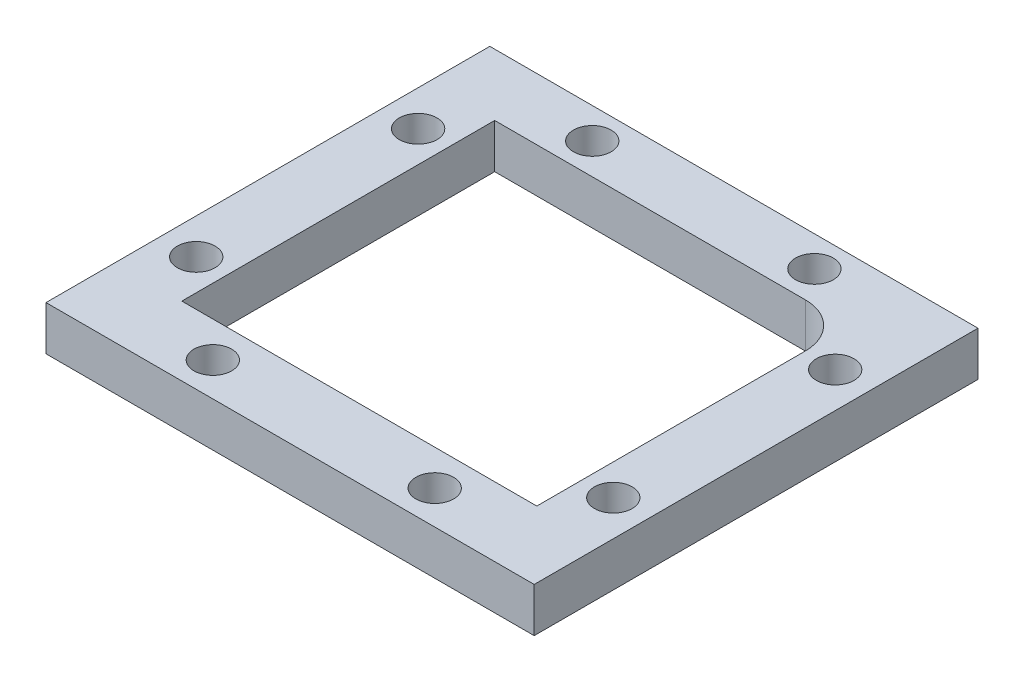
from build123d import *

# Parameters (mm, degrees)
CROQUIS1_R                              = 15.25
CROQUIS1_R_2                            = 2.125
SOPORTE_CAJA_REDUCTORA_DEPTH            = 20
CROQUIS3_R                              = 2.125
CORTAR_EXTRUIR1_DEPTH                   = 51.423828692
REDONDEO1_R                             = 5
BOSS_EXTRUDE1_DEPTH                     = 20
CUT_EXTRUDE1_REACH                      = 55.852
SKETCH2_R                               = 1.625
CUT_EXTRUDE2_DEPTH                      = 2
SKETCH4_R                               = 1.625
CUT_EXTRUDE3_DEPTH                      = 63.291652731
CUT_EXTRUDE4_START                      = -4.5
CUT_EXTRUDE4_DEPTH                      = 2
CROQUIS6_W                              = 4.75
CROQUIS6_H                              = 4.75
CORTAR_EXTRUIR17_DEPTH                  = 42.231056256
CROQUIS7_W                              = 60
CROQUIS7_H                              = 20
CORTAR_EXTRUIR18_DEPTH                  = 51.423828692
SALIENTE_EXTRUIR2_DEPTH                 = 49
SOPORTE_START                           = -15
SOPORTE_MOTOR_DEPTH                     = 15
CROQUIS12_R                             = 2.125
AGUJEROS_DE_SUJECION_A_BASE_DEPTH       = 84.087679592
TUERCA_START                            = -4
TUERCA_AGUJERO_DE_SUJECION_A_BASE_DEPTH = 10
SALIENTE_EXTRUIR4_DEPTH                 = 15
CORTAR_EXTRUIR19_DEPTH                  = 25
CROQUIS14_W                             = 50
CROQUIS14_H                             = 118
CORTAR_EXTRUIR22_DEPTH                  = 146.556045907
CROQUIS15_W                             = 10
CROQUIS15_H                             = 7
CORTAR_EXTRUIR23_DEPTH                  = 42.231056256
CORTAR_EXTRUIR24_DEPTH                  = 42.231056256
CROQUIS18_W                             = 40
CROQUIS18_H                             = 10
CORTAR_EXTRUIR25_DEPTH                  = 44.27311521
SALIENTE_EXTRUIR5_DEPTH                 = 10
CROQUIS20_R                             = 1
CORTAR_EXTRUIR26_DEPTH                  = 49.229270158
CORTAR_EXTRUIR27_REACH                  = 62.959
CORTAR_EXTRUIR27_END_RADIUS             = 15.25
CROQUIS21_R                             = 1.625
CROQUIS22_R                             = 2.125
CROQUIS22_R_2                           = 1
SALIENTE_EXTRUIR6_DEPTH                 = 10
CROQUIS23_R                             = 1.625
CORTAR_EXTRUIR28_DEPTH                  = 52.269508521
CORTAR_EXTRUIR29_START                  = -3
CORTAR_EXTRUIR29_DEPTH                  = 10
SALIENTE_EXTRUIR7_DEPTH                 = 10
CORTAR_EXTRUIR30_REACH                  = 72.235
CROQUIS27_R                             = 1.625
CORTAR_EXTRUIR31_REACH                  = 75.235
CORTAR_EXTRUIR31_START                  = -3
CORTAR_EXTRUIR32_REACH                  = 58.612
CROQUIS29_R                             = 1.625
CORTAR_EXTRUIR33_REACH                  = 61.112
CORTAR_EXTRUIR33_START                  = -2.5
CROQUIS35_W                             = 13.305418987
CROQUIS35_H                             = 6.826864192
CORTAR_EXTRUIR34_DEPTH                  = 63.931555098
CORTAR_EXTRUIR34_DEPTH_BACK             = 63.931555098
CORTAR_EXTRUIR35_START                  = -3
CORTAR_EXTRUIR35_DEPTH                  = 10
SALIENTE_EXTRUIR8_DEPTH                 = 10
SALIENTE_EXTRUIR9_DEPTH                 = 13
SALIENTE_EXTRUIR10_DEPTH                = 3
CROQUIS40_W                             = 106.583537839
CROQUIS40_H                             = 47.391515964
CORTAR_EXTRUIR36_DEPTH                  = 80.887064817
CORTAR_EXTRUIR36_DEPTH_BACK             = 80.887064817
CORTAR_EXTRUIR37_DEPTH                  = 67.2524009
CORTAR_EXTRUIR37_DEPTH_BACK             = 67.2524009
CORTAR_EXTRUIR38_DEPTH                  = 79.704784639
CORTAR_EXTRUIR38_DEPTH_BACK             = 79.704784639
SALIENTE_EXTRUIR11_DEPTH                = 10
CORTAR_EXTRUIR39_DEPTH                  = 63.9908649
CROQUIS45_W                             = 31.470301378
CROQUIS45_H                             = 10
CROQUIS45_R                             = 1.625
SALIENTE_EXTRUIR12_DEPTH                = 2.5
SALIENTE_EXTRUIR13_DEPTH                = 10
CORTAR_EXTRUIR40_START                  = -2
CROQUIS47_R                             = 1.625
CORTAR_EXTRUIR40_DEPTH                  = 10
CORTAR_EXTRUIR41_START                  = -12
CROQUIS48_R                             = 1.625
CORTAR_EXTRUIR41_DEPTH                  = 12
CROQUIS49_W                             = 34.796066513
CROQUIS49_H                             = 42.211026982
CORTAR_EXTRUIR42_DEPTH                  = 52.795622989
CORTAR_EXTRUIR42_DEPTH_BACK             = 52.795622989
CROQUIS51_R                             = 15.25
CROQUIS51_R_2                           = 14.25
SALIENTE_EXTRUIR14_DEPTH                = 10
CORTAR_EXTRUIR43_DEPTH                  = 10
CORTAR_EXTRUIR44_DEPTH                  = 10
CORTAR_EXTRUIR45_DEPTH                  = 10
SALIENTE_EXTRUIR15_DEPTH                = 10
CROQUIS56_W                             = 55
CROQUIS56_H                             = 50
SALIENTE_EXTRUIR16_DEPTH                = 5
CROQUIS57_W                             = 42.651963039
CROQUIS57_H                             = 12.802181648
CORTAR_EXTRUIR46_DEPTH                  = 71.545387859
CORTAR_EXTRUIR46_DEPTH_BACK             = 71.545387859
CROQUIS58_R                             = 2.125
CORTAR_EXTRUIR47_DEPTH                  = 5


with BuildPart() as part:
    # Croquis1 → Soporte caja reductora (new body)
    with BuildSketch(Plane(origin=(0, 0, 0), x_dir=(1, 0, 0), z_dir=(0, 1, 0))):
        Polygon((-30, -15.25), (-20, -15.25), (-20, -20), (20, -20), (20, -15.25), (30, -15.25), (30, -7.25), (20, -4.25), (20, 20), (-20, 20), (-20, -4.25), (-30, -7.25), align=None)
        with Locations(Location((0, 0, 0), (0, 0, 270))):
            Circle(CROQUIS1_R, mode=Mode.SUBTRACT)
        with Locations(Location((-15, 15, 0), (0, 0, 270))):
            Circle(CROQUIS1_R_2, mode=Mode.SUBTRACT)
        with Locations(Location((15, 15, 0), (0, 0, 270))):
            Circle(CROQUIS1_R_2, mode=Mode.SUBTRACT)
    extrude(amount=-SOPORTE_CAJA_REDUCTORA_DEPTH)

    # Croquis3 → Cortar-Extruir1 (cut, through all)
    with BuildSketch(Plane.XY.offset(15.25)):
        with Locations((-23.5, -10)):
            Circle(CROQUIS3_R)
        with Locations((23.5, -10)):
            Circle(CROQUIS3_R)
    extrude(amount=-CORTAR_EXTRUIR1_DEPTH, mode=Mode.SUBTRACT)

    # Redondeo1
    redondeo1_edges = [part.edges().sort_by_distance(p)[0] for p in [
        (-20, -10, -20),
        (20, -10, -20),
    ]]
    fillet(redondeo1_edges, radius=REDONDEO1_R)

    # Sketch1 → Boss-Extrude1 (add)
    with BuildSketch(Plane(origin=(0, 0, 0), x_dir=(1, 0, 0), z_dir=(0, 1, 0))):
        with BuildLine():
            Line((25.5, 15), (20, 15))
            ThreePointArc((20, 15), (18.535533906, 18.535533906), (15, 20))
            Line((15, 20), (30, 20))
            Line((30, 20), (30, 8))
            Line((30, 8), (25.5, 8))
            Line((25.5, 8), (25.5, 15))
        make_face()
    extrude(amount=-BOSS_EXTRUDE1_DEPTH)

    # Sketch2 → Cut-Extrude1 (cut, up to next)
    with BuildSketch(Plane(origin=(0, 0, -20), x_dir=(-1, 0, 0), z_dir=(0, 0, -1)), mode=Mode.PRIVATE) as cut_extrude1_sk1:
        with Locations((-22.75, -10)):
            Circle(SKETCH2_R)
    cut_extrude1_tool1 = extrude(cut_extrude1_sk1.sketch, amount=-CUT_EXTRUDE1_REACH, mode=Mode.PRIVATE) & part.part
    add(cut_extrude1_tool1.solids().sort_by_distance((22.75, -10, -20))[0], mode=Mode.SUBTRACT)

    # Sketch3 → Cut-Extrude2 (cut)
    with BuildSketch(Plane.XY.offset(-15)):
        Polygon((20, -11.58771324), (22.75, -13.175426481), (25.5, -11.58771324), (25.5, -8.41228676), (22.75, -6.824573519), (20, -8.41228676), align=None)
    extrude(amount=-CUT_EXTRUDE2_DEPTH, mode=Mode.SUBTRACT)

    # Sketch4 → Cut-Extrude3 (cut, through all)
    with BuildSketch(Plane.ZY.offset(-25.5)):
        with Locations((-12.25, -10)):
            Circle(SKETCH4_R)
    extrude(amount=-CUT_EXTRUDE3_DEPTH, mode=Mode.SUBTRACT)

    # Sketch5 → Cut-Extrude4 (cut)
    with BuildSketch(Plane(origin=(30, 0, 0), x_dir=(0, 0, -1), z_dir=(1, 0, 0)).offset(CUT_EXTRUDE4_START)):
        Polygon((15, -11.58771324), (15, -8.41228676), (12.25, -6.824573519), (9.5, -8.41228676), (9.5, -11.58771324), (12.25, -13.175426481), align=None)
    extrude(amount=CUT_EXTRUDE4_DEPTH, mode=Mode.SUBTRACT)

    # Croquis6 → Cortar-Extruir17 (cut, through all)
    with BuildSketch(Plane(origin=(0, 0, 0), x_dir=(1, 0, 0), z_dir=(0, 1, 0))):
        Polygon((0, -15.25), (-15.25, -15.25), (-15.25, -20), (15.25, -20), (15.25, -15.25), align=None)
        with Locations((-17.625, -17.625)):
            Rectangle(CROQUIS6_W, CROQUIS6_H)
        with BuildLine():
            ThreePointArc((0, -15.25), (-10.783378413, -10.783378413), (-15.25, 0))
            Line((-15.25, 0), (-15.25, -15.25))
            Line((-15.25, -15.25), (0, -15.25))
        make_face()
        with BuildLine():
            Line((15.25, -15.25), (15.25, 0))
            ThreePointArc((15.25, 0), (10.783378413, -10.783378413), (0, -15.25))
            Line((0, -15.25), (15.25, -15.25))
        make_face()
        with Locations((17.625, -17.625)):
            Rectangle(CROQUIS6_W, CROQUIS6_H)
    extrude(amount=-CORTAR_EXTRUIR17_DEPTH, mode=Mode.SUBTRACT)


with BuildPart() as body_2:
    # Simetría1: mirrored copy
    add(part.part.mirror(Plane.ZX))

    # Croquis8 → Saliente-Extruir2 (add)
    with BuildSketch(Plane(origin=(0, 20, 0), x_dir=(1, 0, 0), z_dir=(0, 1, 0))):
        with BuildLine():
            Line((-12.664515522, 20), (-11.040489496, 13.939052358))
            Line((-11.040489496, 13.939052358), (-10.315162126, 11.232093763))
            ThreePointArc((-10.315162126, 11.232093763), (0, 15.25), (10.315162126, 11.232093763))
            Line((10.315162126, 11.232093763), (10.817418481, 13.87928066))
            Line((10.817418481, 13.87928066), (11.978715476, 20))
            Line((11.978715476, 20), (-12.664515522, 20))
        make_face()
    extrude(amount=SALIENTE_EXTRUIR2_DEPTH)

    # Croquis9 → Soporte motor (add)
    with BuildSketch(Plane(origin=(0, 69, 0), x_dir=(1, 0, 0), z_dir=(0, 1, 0)).offset(SOPORTE_START)):
        with BuildLine():
            Line((-20, 15), (-20, -4.25))
            Line((-20, -4.25), (-30, -7.25))
            Line((-30, -7.25), (-30, -15.25))
            Line((-30, -15.25), (0, -15.25))
            Line((0, -15.25), (0, -14.75))
            ThreePointArc((0, -14.75), (-10.429825023, 10.429825023), (14.75, 0))
            Line((14.75, 0), (20, 0))
            Line((20, 0), (20, 13.936837101))
            Line((20, 13.936837101), (12.664515522, 20))
            Line((12.664515522, 20), (-15, 20))
            ThreePointArc((-15, 20), (-18.535533906, 18.535533906), (-20, 15))
        make_face()
    extrude(amount=-SOPORTE_MOTOR_DEPTH)

    # Croquis12 → Agujeros de sujecion a base (cut, through all)
    with BuildSketch(Plane.XY.offset(15.25)):
        with Locations((-23.5, 46.5)):
            Circle(CROQUIS12_R)
    extrude(amount=-AGUJEROS_DE_SUJECION_A_BASE_DEPTH, mode=Mode.SUBTRACT)

    # Croquis13 → Tuerca Agujero de sujecion a base (cut)
    with BuildSketch(Plane.XY.offset(15.25).offset(TUERCA_START)):
        Polygon((-20, 44.479274058), (-20, 48.520725942), (-23.5, 50.541451884), (-27, 48.520725942), (-27, 44.479274058), (-23.5, 42.458548116), align=None)
    extrude(amount=-TUERCA_AGUJERO_DE_SUJECION_A_BASE_DEPTH, mode=Mode.SUBTRACT)

    # Croquis10 → Saliente-Extruir4 (add)
    with BuildSketch(Plane(origin=(0, 69, 0), x_dir=(1, 0, 0), z_dir=(0, 1, 0))):
        with BuildLine():
            ThreePointArc((10.315162126, 11.232093763), (0, 15.25), (-10.315162126, 11.232093763))
            Line((-10.315162126, 11.232093763), (-10.16850369, 10.684757026))
            ThreePointArc((-10.16850369, 10.684757026), (0, 14.75), (10.16850369, 10.684757026))
            Line((10.16850369, 10.684757026), (10.315162126, 11.232093763))
        make_face()
    extrude(amount=-SALIENTE_EXTRUIR4_DEPTH)

    # Croquis11 → Cortar-Extruir19 (cut)
    with BuildSketch(Plane.XZ):
        with BuildLine():
            Line((15.25, 4.25), (20, 4.25))
            Line((20, 4.25), (21.972856468, 4.84185694))
            ThreePointArc((21.972856468, 4.84185694), (19.948931102, 10.40625523), (16.543503257, 15.25))
            Line((16.543503257, 15.25), (15.25, 15.25))
            Line((15.25, 15.25), (15.25, 4.25))
        make_face()
        with BuildLine():
            Line((21.972856468, 4.84185694), (30, 7.25))
            Line((30, 7.25), (30, 15.25))
            Line((30, 15.25), (16.543503257, 15.25))
            ThreePointArc((16.543503257, 15.25), (19.948931102, 10.40625523), (21.972856468, 4.84185694))
        make_face()
        with BuildLine():
            ThreePointArc((20, -15), (18.535533906, -18.535533906), (15, -20))
            Line((15, -20), (30, -20))
            Line((30, -20), (30, -8))
            Line((30, -8), (25.5, -8))
            Line((25.5, -8), (25.5, -15))
            Line((25.5, -15), (20, -15))
        make_face()
    extrude(amount=-CORTAR_EXTRUIR19_DEPTH, mode=Mode.SUBTRACT)

    # Simetría2: body 2 across face


with BuildPart() as part_1:
    add(part.part)

    # Croquis7 → Cortar-Extruir18 (cut, through all)
    with BuildSketch(Plane(origin=(0, 0, -20), x_dir=(-1, 0, 0), z_dir=(0, 0, -1))):
        with Locations((0, -10)):
            Rectangle(CROQUIS7_W, CROQUIS7_H)
    extrude(amount=-CORTAR_EXTRUIR18_DEPTH, mode=Mode.SUBTRACT)


with BuildPart() as body_2_1:
    add(body_2.part)
    add(body_2.part.mirror(Plane(origin=(-0.229209569, 69, -16.663998028), x_dir=(0, 0, 1), z_dir=(0, 1, 0))))

    # Croquis14 → Cortar-Extruir22 (cut, through all)
    with BuildSketch(Plane.XY.offset(15.25)):
        with Locations((-5, 79)):
            Rectangle(CROQUIS14_W, CROQUIS14_H)
    extrude(amount=-CORTAR_EXTRUIR22_DEPTH, mode=Mode.SUBTRACT)

    # Croquis15 → Cortar-Extruir23 (cut, through all)
    with BuildSketch(Plane.XZ):
        with Locations((-25, 7.75)):
            Rectangle(CROQUIS15_W, CROQUIS15_H)
    extrude(amount=-CORTAR_EXTRUIR23_DEPTH, mode=Mode.SUBTRACT)

    # Croquis16 → Cortar-Extruir24 (cut, through all)
    with BuildSketch(Plane.XZ):
        Polygon((-30, 15.25), (-15.25, 15.25), (-15.25, 12.75), (-20, 12.75), (-20, 11.25), (-30, 11.25), (-30, 12.75), align=None)
    extrude(amount=-CORTAR_EXTRUIR24_DEPTH, mode=Mode.SUBTRACT)

    # Croquis18 → Cortar-Extruir25 (cut, through all)
    with BuildSketch(Plane(origin=(0, 0, -20), x_dir=(-1, 0, 0), z_dir=(0, 0, -1))):
        with Locations((0, 5)):
            Rectangle(CROQUIS18_W, CROQUIS18_H)
    extrude(amount=-CORTAR_EXTRUIR25_DEPTH, mode=Mode.SUBTRACT)

    # Croquis19 → Saliente-Extruir5 (add)
    with BuildSketch(Plane(origin=(0, 20, 0), x_dir=(1, 0, 0), z_dir=(0, 1, 0))):
        Polygon((-20, -12.75), (-34, -12.75), (-34, -7.75), (-24, -7.75), (-20, -3.75), align=None)
    extrude(amount=-SALIENTE_EXTRUIR5_DEPTH)

    # Croquis20 → Cortar-Extruir26 (cut, through all)
    with BuildSketch(Plane(origin=(0, 0, 7.75), x_dir=(-1, 0, 0), z_dir=(0, 0, -1))):
        with Locations((29, 15)):
            Circle(CROQUIS20_R)
    extrude(amount=-CORTAR_EXTRUIR26_DEPTH, mode=Mode.SUBTRACT)

    # Cortar-Extruir27: up to this cylinder (the profile starts outside it)
    cortar_extruir27_end = Plane(origin=(0, 15, 0), z_dir=(0, -1, 0)) * Cylinder(CORTAR_EXTRUIR27_END_RADIUS, 157.418, mode=Mode.PRIVATE)
    # Croquis21 → Cortar-Extruir27 (cut, up to the surface)
    with BuildSketch(Plane(origin=(20, 0, 0), x_dir=(0, 0, -1), z_dir=(1, 0, 0)), mode=Mode.PRIVATE) as cortar_extruir27_sk1:
        with Locations((4.75, 15)):
            Circle(CROQUIS21_R)
    cortar_extruir27_tool1 = extrude(cortar_extruir27_sk1.sketch, amount=-CORTAR_EXTRUIR27_REACH, mode=Mode.PRIVATE) - cortar_extruir27_end
    add(cortar_extruir27_tool1.solids().sort_by_distance((20, 15, -4.75))[0], mode=Mode.SUBTRACT)

    # Croquis22 → Saliente-Extruir6 (add)
    with BuildSketch(Plane.XZ.offset(-10)):
        with Locations((-15, -15)):
            Circle(CROQUIS22_R)
        with Locations(Location((-15, -15, 0), (0, 0, 270))):
            Circle(CROQUIS22_R_2, mode=Mode.SUBTRACT)
        with Locations((15, -15)):
            Circle(CROQUIS22_R)
        with Locations(Location((15, -15, 0), (0, 0, 270))):
            Circle(CROQUIS22_R_2, mode=Mode.SUBTRACT)
    extrude(amount=-SALIENTE_EXTRUIR6_DEPTH)

    # Croquis23 → Cortar-Extruir28 (cut, through all)
    with BuildSketch(Plane(origin=(0, 0, -20), x_dir=(-1, 0, 0), z_dir=(0, 0, -1))):
        with Locations((0, 15)):
            Circle(CROQUIS23_R)
    extrude(amount=-CORTAR_EXTRUIR28_DEPTH, mode=Mode.SUBTRACT)

    # Croquis24 → Cortar-Extruir29 (cut)
    with BuildSketch(Plane(origin=(0, 0, -20), x_dir=(-1, 0, 0), z_dir=(0, 0, -1)).offset(CORTAR_EXTRUIR29_START)):
        Polygon((1.58771324, 12.25), (3.175426481, 15), (1.58771324, 17.75), (-1.58771324, 17.75), (-3.175426481, 15), (-1.58771324, 12.25), align=None)
    extrude(amount=-CORTAR_EXTRUIR29_DEPTH, mode=Mode.SUBTRACT)

    # Croquis26 → Saliente-Extruir7 (add)
    with BuildSketch(Plane.XZ.offset(-10)):
        Polygon((-34, 7.75), (-34, 12.75), (-58.825, 12.75), (-39.160527763, -4.104491148), (-20, -4.104491148), (-20, -0.104491148), (-35.732113118, -0.104491148), (-29, 7.75), align=None)
        Polygon((-34.268209086, 7.75), (-39.594516123, 1.535690951), (-46.844874897, 7.75), align=None, mode=Mode.SUBTRACT)
    extrude(amount=-SALIENTE_EXTRUIR7_DEPTH)

    # Croquis27 → Cortar-Extruir30 (cut, up to next)
    with BuildSketch(Plane.XY.offset(12.75), mode=Mode.PRIVATE) as cortar_extruir30_sk1:
        with Locations((-40.544874897, 15)):
            Circle(CROQUIS27_R)
    cortar_extruir30_tool1 = extrude(cortar_extruir30_sk1.sketch, amount=-CORTAR_EXTRUIR30_REACH, mode=Mode.PRIVATE) & body_2_1.part
    # Croquis27 → Cortar-Extruir30 (cut, up to next)
    with BuildSketch(Plane.XY.offset(12.75), mode=Mode.PRIVATE) as cortar_extruir30_sk2:
        with Locations((-29, 15)):
            Circle(CROQUIS27_R)
    cortar_extruir30_tool2 = extrude(cortar_extruir30_sk2.sketch, amount=-CORTAR_EXTRUIR30_REACH, mode=Mode.PRIVATE) & body_2_1.part
    add(cortar_extruir30_tool1.solids().sort_by_distance((-40.544875, 15, 12.75))[0], mode=Mode.SUBTRACT)
    add(cortar_extruir30_tool2.solids().sort_by_distance((-29, 15, 12.75))[0], mode=Mode.SUBTRACT)

    # Croquis28 → Cortar-Extruir31 (cut, up to next)
    with BuildSketch(Plane.XY.offset(12.75).offset(CORTAR_EXTRUIR31_START), mode=Mode.PRIVATE) as cortar_extruir31_sk1:
        Polygon((-38.957161657, 12.25), (-37.369448416, 15), (-38.957161657, 17.75), (-42.132588137, 17.75), (-43.720301378, 15), (-42.132588137, 12.25), align=None)
    cortar_extruir31_tool1 = extrude(cortar_extruir31_sk1.sketch, amount=-CORTAR_EXTRUIR31_REACH, mode=Mode.PRIVATE) & body_2_1.part
    # Croquis28 → Cortar-Extruir31 (cut, up to next)
    with BuildSketch(Plane.XY.offset(12.75).offset(CORTAR_EXTRUIR31_START), mode=Mode.PRIVATE) as cortar_extruir31_sk2:
        Polygon((-27.41228676, 12.25), (-25.824573519, 15), (-27.41228676, 17.75), (-30.58771324, 17.75), (-32.175426481, 15), (-30.58771324, 12.25), align=None)
    cortar_extruir31_tool2 = extrude(cortar_extruir31_sk2.sketch, amount=-CORTAR_EXTRUIR31_REACH, mode=Mode.PRIVATE) & body_2_1.part
    add(cortar_extruir31_tool1.solids().sort_by_distance((-40.544875, 15, 9.75))[0], mode=Mode.SUBTRACT)
    add(cortar_extruir31_tool2.solids().sort_by_distance((-29, 15, 9.75))[0], mode=Mode.SUBTRACT)

    # Croquis29 → Cortar-Extruir32 (cut, up to next)
    with BuildSketch(Plane(origin=(-18.612848159, 0, -21.715982563), x_dir=(-0.7592713073348843, 0, 0.6507742172658468), z_dir=(-0.6507742172658468, 0, -0.7592713073348843)), mode=Mode.PRIVATE) as cortar_extruir32_sk1:
        with Locations((33.812368097, 15)):
            Circle(CROQUIS29_R)
    cortar_extruir32_tool1 = extrude(cortar_extruir32_sk1.sketch, amount=-CORTAR_EXTRUIR32_REACH, mode=Mode.PRIVATE) & body_2_1.part
    add(cortar_extruir32_tool1.solids().sort_by_distance((-44.285609, 15, 0.288235))[0], mode=Mode.SUBTRACT)

    # Croquis31 → Cortar-Extruir33 (cut, up to next)
    with BuildSketch(Plane(origin=(-18.612848159, 0, -21.715982563), x_dir=(-0.7592713073348843, 0, 0.6507742172658468), z_dir=(-0.6507742172658468, 0, -0.7592713073348843)).offset(CORTAR_EXTRUIR33_START), mode=Mode.PRIVATE) as cortar_extruir33_sk1:
        Polygon((36.562368097, 16.58771324), (33.812368097, 18.175426481), (31.062368097, 16.58771324), (31.062368097, 13.41228676), (33.812368097, 11.824573519), (36.562368097, 13.41228676), align=None)
    cortar_extruir33_tool1 = extrude(cortar_extruir33_sk1.sketch, amount=-CORTAR_EXTRUIR33_REACH, mode=Mode.PRIVATE) & body_2_1.part
    add(cortar_extruir33_tool1.solids().sort_by_distance((-42.658674, 15, 2.186413))[0], mode=Mode.SUBTRACT)

    # Croquis35 → Cortar-Extruir34 (cut, two sides)
    with BuildSketch(Plane(origin=(0, 20, 0), x_dir=(1, 0, 0), z_dir=(0, 1, 0))) as cortar_extruir34_sk:
        with Locations((17.04227466, -3.413432096)):
            Rectangle(CROQUIS35_W, CROQUIS35_H)
    extrude(amount=CORTAR_EXTRUIR34_DEPTH, mode=Mode.SUBTRACT)
    extrude(cortar_extruir34_sk.sketch, amount=-CORTAR_EXTRUIR34_DEPTH_BACK, mode=Mode.SUBTRACT)

    # Croquis36 → Cortar-Extruir35 (cut)
    with BuildSketch(Plane(origin=(20, 0, 0), x_dir=(0, 0, -1), z_dir=(1, 0, 0)).offset(CORTAR_EXTRUIR35_START)):
        Polygon((7.5, 16.58771324), (4.75, 18.175426481), (2, 16.58771324), (2, 13.41228676), (4.75, 11.824573519), (7.5, 13.41228676), align=None)
    extrude(amount=-CORTAR_EXTRUIR35_DEPTH, mode=Mode.SUBTRACT)

    # Croquis37 → Saliente-Extruir8 (add)
    with BuildSketch(Plane.XZ.offset(-10)):
        Polygon((-39.160527763, -4.104491148), (-20.614919368, -20), (-15, -20), (-19.558128305, -15.637570403), (-33.014002756, -4.104491148), align=None)
    extrude(amount=-SALIENTE_EXTRUIR8_DEPTH)

    # Croquis38 → Saliente-Extruir9 (add)
    with BuildSketch(Plane.XZ.offset(-10)):
        Polygon((-58.825, 12.75), (-38.825, 12.75), (-38.825, 9.75), (-55.324839942, 9.75), align=None)
    extrude(amount=SALIENTE_EXTRUIR9_DEPTH)

    # Croquis39 → Saliente-Extruir10 (add)
    with BuildSketch(Plane.XZ.offset(-10)):
        Polygon((-38.825, 9.75), (-38.825, 7.75), (-38.825, 5.75), (-50.657959865, 5.75), (-52.991399903, 7.75), (-55.324839942, 9.75), align=None)
    extrude(amount=SALIENTE_EXTRUIR10_DEPTH)

    # Simetría3: body 2 across face


with BuildPart() as body_2_2:
    add(body_2_1.part)
    add(body_2_1.part.mirror(Plane(origin=(-18.003999227, 20, -4.220503046), x_dir=(0, 0, 1), z_dir=(0, 1, 0))))

    # Croquis40 → Cortar-Extruir36 (cut, two sides)
    with BuildSketch(Plane(origin=(0, 0, -20), x_dir=(-1, 0, 0), z_dir=(0, 0, -1))) as cortar_extruir36_sk:
        with Locations((22.395502026, -3.695757982)):
            Rectangle(CROQUIS40_W, CROQUIS40_H)
    extrude(amount=CORTAR_EXTRUIR36_DEPTH, mode=Mode.SUBTRACT)
    extrude(cortar_extruir36_sk.sketch, amount=-CORTAR_EXTRUIR36_DEPTH_BACK, mode=Mode.SUBTRACT)

    # Croquis41 → Cortar-Extruir37 (cut, two sides)
    with BuildSketch(Plane.XZ.offset(-20)) as cortar_extruir37_sk:
        Polygon((-19.992980133, -22.302484261), (-20, 3.75), (-24, 7.75), (-56.035110209, 7.75), align=None)
    extrude(amount=CORTAR_EXTRUIR37_DEPTH, mode=Mode.SUBTRACT)
    extrude(cortar_extruir37_sk.sketch, amount=-CORTAR_EXTRUIR37_DEPTH_BACK, mode=Mode.SUBTRACT)

    # Croquis42 → Cortar-Extruir38 (cut, two sides)
    with BuildSketch(Plane(origin=(0, 0, 9.75), x_dir=(-1, 0, 0), z_dir=(0, 0, -1))) as cortar_extruir38_sk:
        Polygon((46.720301378, 20), (46.720301378, 30), (38.825, 30), (33.492952769, 43.760628779), (49.525340398, 48.951442806), (67.200390695, 42.512205152), (65.906601328, 20), (51.713995885, 13.864168239), align=None)
    extrude(amount=CORTAR_EXTRUIR38_DEPTH, mode=Mode.SUBTRACT)
    extrude(cortar_extruir38_sk.sketch, amount=-CORTAR_EXTRUIR38_DEPTH_BACK, mode=Mode.SUBTRACT)

    # Croquis43 → Saliente-Extruir11 (add)
    with BuildSketch(Plane.XZ.offset(-20)):
        Polygon((-19.993600539, -20), (-46.720301378, 7.75), (-43.839252857, 10.524807997), (-17.112552018, -17.225192003), align=None)
    extrude(amount=-SALIENTE_EXTRUIR11_DEPTH)

    # Croquis44 → Cortar-Extruir39 (cut, through all)
    with BuildSketch(Plane(origin=(0, 0, 9.75), x_dir=(-1, 0, 0), z_dir=(0, 0, -1))):
        Polygon((38.957161657, 27.75), (37.369448416, 25), (38.957161657, 22.25), (42.132588137, 22.25), (43.720301378, 25), (42.132588137, 27.75), align=None)
    extrude(amount=CORTAR_EXTRUIR39_DEPTH, mode=Mode.SUBTRACT)

    # Croquis45 → Saliente-Extruir12 (add)
    with BuildSketch(Plane.XY.offset(12.75)):
        with Locations((-30.985150689, 25)):
            Rectangle(CROQUIS45_W, CROQUIS45_H)
        with Locations((-40.544874897, 25)):
            Circle(CROQUIS45_R, mode=Mode.SUBTRACT)
        with Locations((-29, 25)):
            Circle(CROQUIS45_R, mode=Mode.SUBTRACT)
    extrude(amount=SALIENTE_EXTRUIR12_DEPTH)

    # Croquis46 → Saliente-Extruir13 (add)
    with BuildSketch(Plane.XZ.offset(-20)):
        with BuildLine():
            Line((15.25, 0), (20, 0))
            Line((20, 0), (20, 15.25))
            Line((20, 15.25), (7.549834435, 15.25))
            Line((7.549834435, 15.25), (7.549834435, 13.25))
            ThreePointArc((7.549834435, 13.25), (13.185171124, 7.662490615), (15.25, 0))
        make_face()
        with BuildLine():
            Line((-15.25, 0), (-15.25, 15.25))
            Line((-15.25, 15.25), (-7.549834435, 15.25))
            Line((-7.549834435, 15.25), (-7.549834435, 13.25))
            ThreePointArc((-7.549834435, 13.25), (-13.185171124, 7.662490615), (-15.25, 0))
        make_face()
    extrude(amount=-SALIENTE_EXTRUIR13_DEPTH)

    # Croquis47 → Cortar-Extruir40 (cut)
    with BuildSketch(Plane.XY.offset(15.25).offset(CORTAR_EXTRUIR40_START)):
        Polygon((15.41228676, 22.352505966), (17, 25.102505966), (15.41228676, 27.852505966), (12.236860279, 27.852505966), (10.649147039, 25.102505966), (12.236860279, 22.352505966), align=None)
        with Locations((13.824573519, 25.102505966)):
            Circle(CROQUIS47_R, mode=Mode.SUBTRACT)
        Polygon((-12.236860279, 22.352505966), (-15.41228676, 22.352505966), (-17, 25.102505966), (-15.41228676, 27.852505966), (-12.236860279, 27.852505966), (-10.649147039, 25.102505966), align=None)
        with Locations(Location((-13.824573519, 25.102505966, 0), (0, 0, 131.421584744))):
            Circle(CROQUIS47_R, mode=Mode.SUBTRACT)
    extrude(amount=-CORTAR_EXTRUIR40_DEPTH, mode=Mode.SUBTRACT)

    # Croquis48 → Cortar-Extruir41 (cut)
    with BuildSketch(Plane.XY.offset(15.25).offset(CORTAR_EXTRUIR41_START)):
        with Locations((13.824573519, 25.102505966)):
            Circle(CROQUIS48_R)
        with Locations((-13.824573519, 25.102505966)):
            Circle(CROQUIS48_R)
    extrude(amount=CORTAR_EXTRUIR41_DEPTH, mode=Mode.SUBTRACT)

    # Croquis49 → Cortar-Extruir42 (cut, two sides)
    with BuildSketch(Plane.XZ.offset(-20)) as cortar_extruir42_sk:
        with Locations((-37.391633796, 1.105513491)):
            Rectangle(CROQUIS49_W, CROQUIS49_H)
    extrude(amount=CORTAR_EXTRUIR42_DEPTH, mode=Mode.SUBTRACT)
    extrude(cortar_extruir42_sk.sketch, amount=-CORTAR_EXTRUIR42_DEPTH_BACK, mode=Mode.SUBTRACT)

    # Croquis51 → Saliente-Extruir14 (add)
    with BuildSketch(Plane(origin=(0, 30, 0), x_dir=(1, 0, 0), z_dir=(0, 1, 0))):
        Circle(CROQUIS51_R)
        with Locations(Location((0, 0, 0), (0, 0, 270))):
            Circle(CROQUIS51_R_2, mode=Mode.SUBTRACT)
    extrude(amount=-SALIENTE_EXTRUIR14_DEPTH)

    # Croquis52 → Cortar-Extruir43 (cut)
    with BuildSketch(Plane(origin=(0, 0, 13.25), x_dir=(-1, 0, 0), z_dir=(0, 0, -1))):
        Polygon((-10.649147039, 25.102505966), (-12.236860279, 27.852505966), (-15.41228676, 27.852505966), (-17, 25.102505966), (-15.41228676, 22.352505966), (-12.236860279, 22.352505966), align=None)
        Polygon((17, 25.102505966), (15.41228676, 27.852505966), (12.236860279, 27.852505966), (10.649147039, 25.102505966), (12.236860279, 22.352505966), (15.41228676, 22.352505966), align=None)
    extrude(amount=CORTAR_EXTRUIR43_DEPTH, mode=Mode.SUBTRACT)

    # Croquis53 → Cortar-Extruir44 (cut)
    with BuildSketch(Plane.XY.offset(-17)):
        Polygon((3.175426481, 25), (1.58771324, 27.75), (-1.58771324, 27.75), (-3.175426481, 25), (-1.58771324, 22.25), (1.58771324, 22.25), align=None)
    extrude(amount=CORTAR_EXTRUIR44_DEPTH, mode=Mode.SUBTRACT)

    # Croquis54 → Cortar-Extruir45 (cut)
    with BuildSketch(Plane.ZY.offset(-17)):
        Polygon((-4.75, 28.175426481), (-7.5, 26.58771324), (-7.5, 23.41228676), (-4.75, 21.824573519), (-2, 23.41228676), (-2, 26.58771324), align=None)
    extrude(amount=CORTAR_EXTRUIR45_DEPTH, mode=Mode.SUBTRACT)

    # Croquis55 → Saliente-Extruir15 (add)
    with BuildSketch(Plane(origin=(0, 30, 0), x_dir=(1, 0, 0), z_dir=(0, 1, 0))):
        with BuildLine():
            Line((-7.549834435, -13.25), (-7.549834435, -15.25))
            Line((-7.549834435, -15.25), (0, -15.25))
            ThreePointArc((0, -15.25), (-3.905124838, -14.741522988), (-7.549834435, -13.25))
        make_face()
        with BuildLine():
            ThreePointArc((7.549834435, -13.25), (3.905124838, -14.741522988), (0, -15.25))
            Line((0, -15.25), (7.549834435, -15.25))
            Line((7.549834435, -15.25), (7.549834435, -13.25))
        make_face()
    extrude(amount=-SALIENTE_EXTRUIR15_DEPTH)

    # Croquis57 → Cortar-Extruir46 (cut, two sides)
    with BuildSketch(Plane.ZY.offset(27.5)) as cortar_extruir46_sk:
        with Locations((1.32598152, 23.598909176)):
            Rectangle(CROQUIS57_W, CROQUIS57_H)
    extrude(amount=CORTAR_EXTRUIR46_DEPTH, mode=Mode.SUBTRACT)
    extrude(cortar_extruir46_sk.sketch, amount=-CORTAR_EXTRUIR46_DEPTH_BACK, mode=Mode.SUBTRACT)


with BuildPart() as body_2_2_1:
    # Croquis56 → Saliente-Extruir16 (new body)
    with BuildSketch(Plane(origin=(0, 30, 0), x_dir=(1, 0, 0), z_dir=(0, 1, 0))):
        with Locations((0, 1.956478778)):
            Rectangle(CROQUIS56_W, CROQUIS56_H)
        with BuildLine():
            Line((20, -15.25), (20, 15))
            ThreePointArc((20, 15), (18.535533906, 18.535533906), (15, 20))
            Line((15, 20), (-19.993600539, 20))
            Line((-19.993600539, 20), (-19.993600539, -15.25))
            Line((-19.993600539, -15.25), (20, -15.25))
        make_face(mode=Mode.SUBTRACT)
    extrude(amount=SALIENTE_EXTRUIR16_DEPTH)

    # Croquis58 → Cortar-Extruir47 (cut)
    with BuildSketch(Plane.XZ.offset(-30)):
        with Locations(Location((-12.5, 19.25, 0), (0, 0, 270))):
            Circle(CROQUIS58_R)
        with Locations(Location((12.5, 19.25, 0), (0, 0, 270))):
            Circle(CROQUIS58_R)
        with Locations(Location((-12.5, -23.5, 0), (0, 0, 270))):
            Circle(CROQUIS58_R)
        with Locations(Location((12.5, -23.526519471, 0), (0, 0, 270))):
            Circle(CROQUIS58_R)
        with Locations(Location((-23.493600539, 10.125, 0), (0, 0, 270))):
            Circle(CROQUIS58_R)
        with Locations(Location((-23.493600539, -14.875, 0), (0, 0, 270))):
            Circle(CROQUIS58_R)
        with Locations(Location((23.493600539, -14.875, 0), (0, 0, 90))):
            Circle(CROQUIS58_R)
        with Locations(Location((23.493600539, 10.125, 0), (0, 0, 90))):
            Circle(CROQUIS58_R)
    extrude(amount=-CORTAR_EXTRUIR47_DEPTH, mode=Mode.SUBTRACT)


solid = body_2_2_1.part
